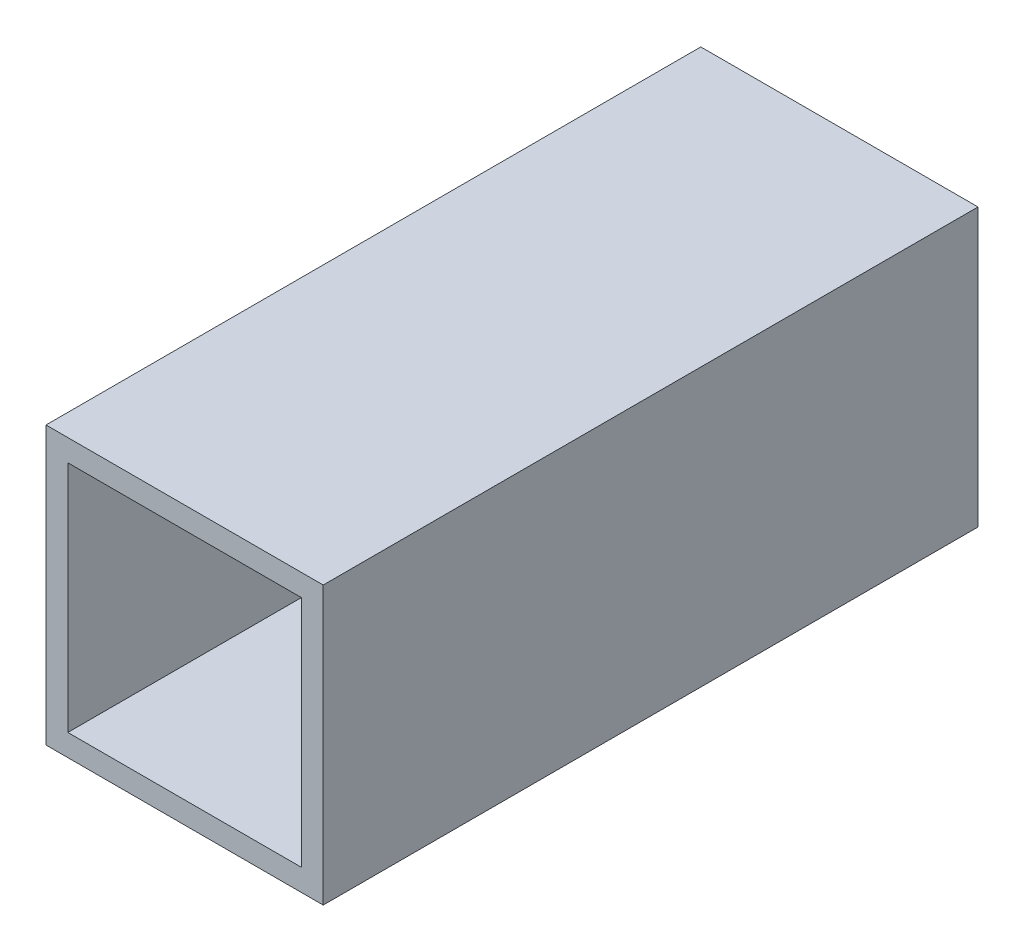
from build123d import *

# Parameters (mm, degrees)
SKETCH1_W           = 25.4
SKETCH1_H           = 25.4
SKETCH1_W_2         = 21.4
SKETCH1_H_2         = 21.4
BOSS_EXTRUDE1_DEPTH = 60


with BuildPart() as part:
    # Sketch1 → Boss-Extrude1 (new body)
    with BuildSketch(Plane.XY):
        Rectangle(SKETCH1_W, SKETCH1_H)
        Rectangle(SKETCH1_W_2, SKETCH1_H_2, mode=Mode.SUBTRACT)
    extrude(amount=BOSS_EXTRUDE1_DEPTH)


solid = part.part
